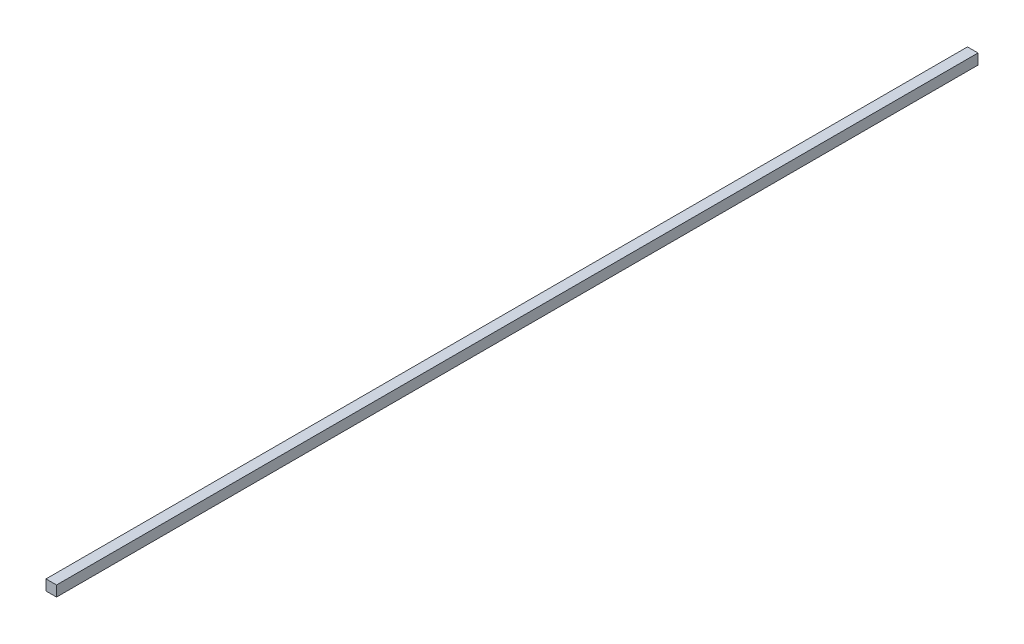
from build123d import *

# Parameters (mm, degrees)
SKETCH3_W                = 4
SKETCH3_H                = 4
BOSS_EXTRUDE1_DEPTH      = 175
BOSS_EXTRUDE1_DEPTH_BACK = 175


with BuildPart() as part:
    # Sketch3 → Boss-Extrude1 (new body, two sides)
    with BuildSketch(Plane.XY) as boss_extrude1_sk:
        Rectangle(SKETCH3_W, SKETCH3_H)
    extrude(amount=BOSS_EXTRUDE1_DEPTH)
    extrude(boss_extrude1_sk.sketch, amount=-BOSS_EXTRUDE1_DEPTH_BACK)


solid = part.part
